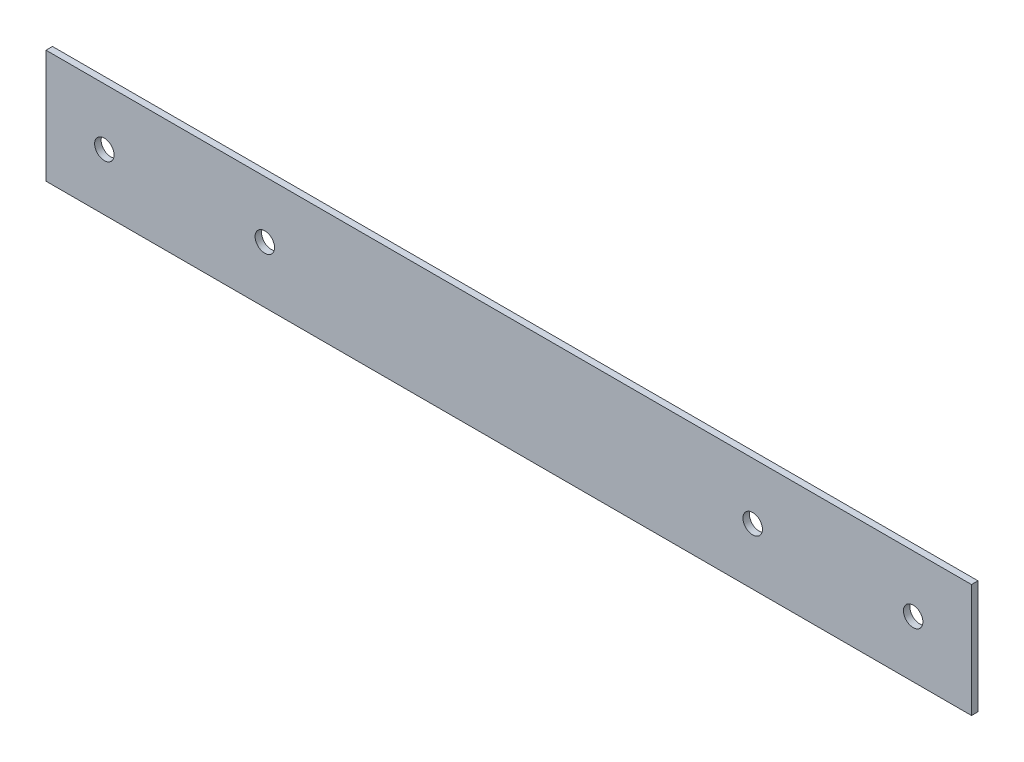
from build123d import *

# Parameters (mm, degrees)
SKETCH1_W           = 285.5
SKETCH1_H           = 35
SKETCH1_R           = 3
BOSS_EXTRUDE1_DEPTH = 2


with BuildPart() as part:
    # Sketch1 → Boss-Extrude1 (new body)
    with BuildSketch(Plane.XY):
        Rectangle(SKETCH1_W, SKETCH1_H)
        with Locations((-124.75, 0)):
            Circle(SKETCH1_R, mode=Mode.SUBTRACT)
        with Locations((-75.25, 0)):
            Circle(SKETCH1_R, mode=Mode.SUBTRACT)
        with Locations((75.25, 0)):
            Circle(SKETCH1_R, mode=Mode.SUBTRACT)
        with Locations((124.75, 0)):
            Circle(SKETCH1_R, mode=Mode.SUBTRACT)
    extrude(amount=BOSS_EXTRUDE1_DEPTH)


solid = part.part
